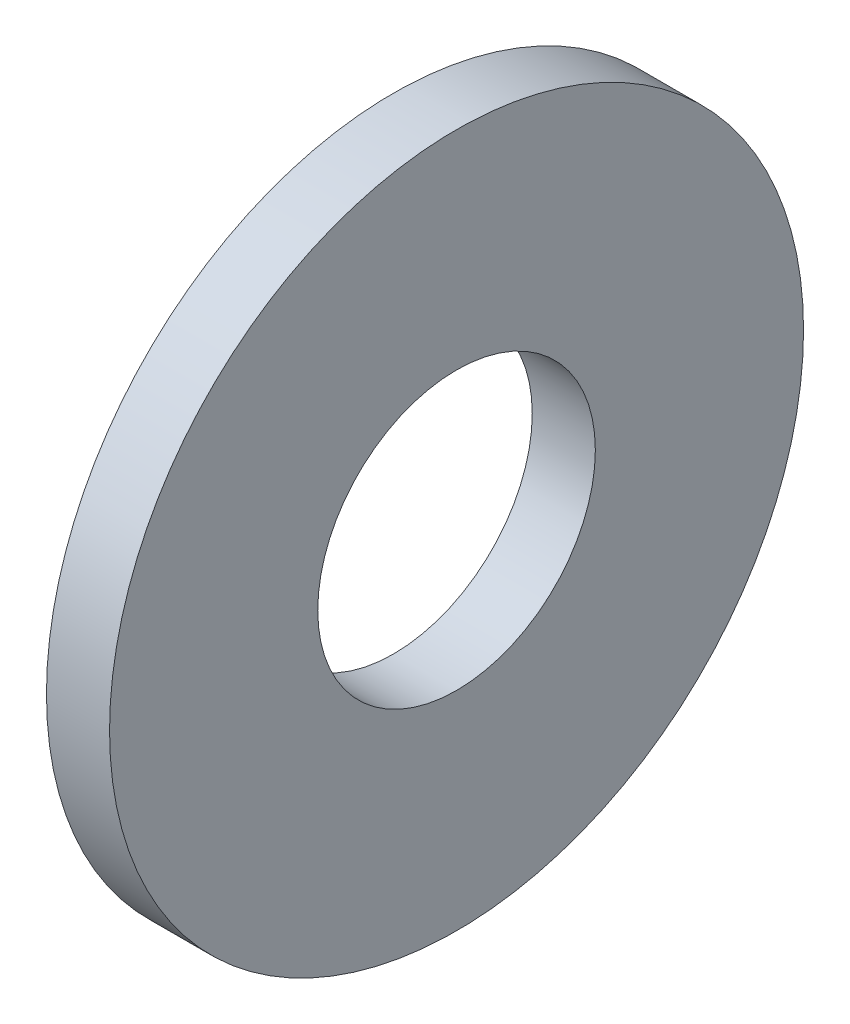
from build123d import *

# Parameters (mm, degrees)
ESQUISSE1_W = 0.5
ESQUISSE1_H = 1.65


with BuildPart() as part:
    # Esquisse1 → Révolution1 (revolve)
    with BuildSketch(Plane(origin=(0, 0, 0), x_dir=(-1, 0, 0), z_dir=(0, 0, -1))):
        with Locations((-0.25, 1.925)):
            Rectangle(ESQUISSE1_W, ESQUISSE1_H)
    revolve(axis=Axis((0.5, 0, 0), (-1, 0, 0)))


solid = part.part
